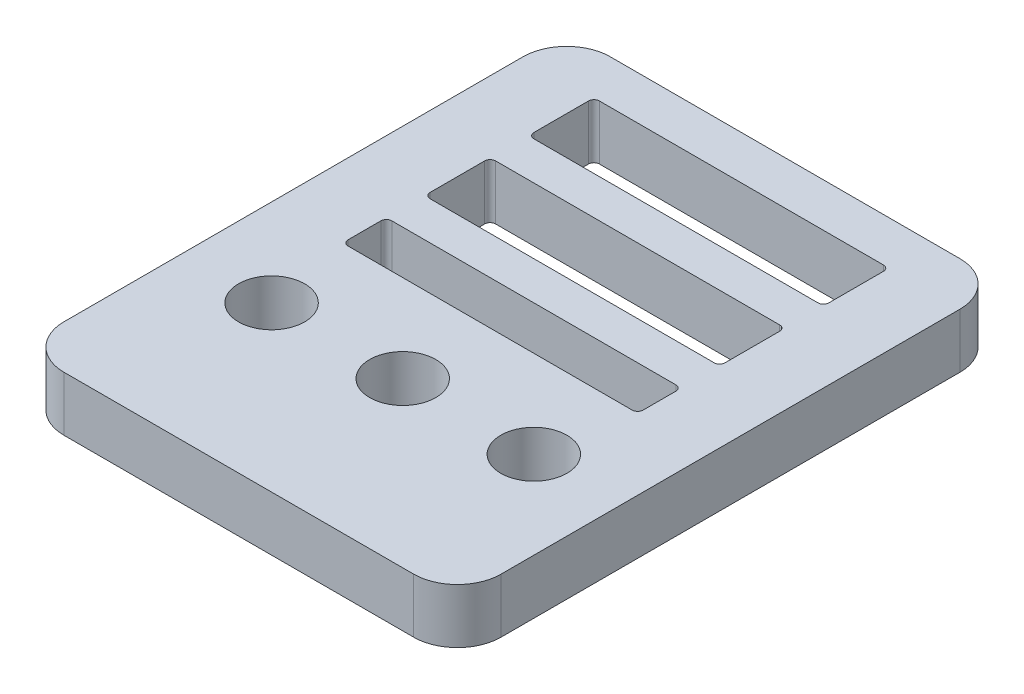
from build123d import *

# Parameters (mm, degrees)
SKETCH1_W           = 40
SKETCH1_H           = 50
BOSS_EXTRUDE1_DEPTH = 5
SKETCH2_W           = 27
SKETCH2_H           = 6
SKETCH2_H_2         = 4
CUT_EXTRUDE1_DEPTH  = 6
SKETCH3_R           = 3.025
CUT_EXTRUDE2_DEPTH  = 6
LPATTERN1_COUNT     = 2
LPATTERN1_PITCH     = 12
LPATTERN1_COL_COUNT = 2
LPATTERN1_COL_PITCH = 12
FILLET1_R           = 4
FILLET2_R           = 0.5


with BuildPart() as part:
    # Sketch1 → Boss-Extrude1 (new body)
    with BuildSketch(Plane(origin=(0, 0, 0), x_dir=(1, 0, 0), z_dir=(0, 1, 0))):
        Rectangle(SKETCH1_W, SKETCH1_H)
    extrude(amount=BOSS_EXTRUDE1_DEPTH)

    # Sketch2 → Cut-Extrude1 (cut, through all)
    with BuildSketch(Plane(origin=(0, 5, 0), x_dir=(1, 0, 0), z_dir=(0, 1, 0))):
        with Locations((0, 18)):
            Rectangle(SKETCH2_W, SKETCH2_H)
        with Locations((0, 8.5)):
            Rectangle(SKETCH2_W, SKETCH2_H)
        Rectangle(SKETCH2_W, SKETCH2_H_2)
    extrude(amount=-CUT_EXTRUDE1_DEPTH, mode=Mode.SUBTRACT)

    # Sketch3 → Cut-Extrude2 (cut, through all)
    with BuildSketch(Plane(origin=(0, 5, 0), x_dir=(1, 0, 0), z_dir=(0, 1, 0))):
        with Locations((0, -10)):
            Circle(SKETCH3_R)
    cut_extrude2 = extrude(amount=-CUT_EXTRUDE2_DEPTH, mode=Mode.SUBTRACT)

    # LPattern1: Cut-Extrude2 ×2
    with Locations(*[(i * LPATTERN1_PITCH, 0, 0) for i in range(1, LPATTERN1_COUNT)]):
        add(cut_extrude2, mode=Mode.SUBTRACT)

    # LPattern1 col: Cut-Extrude2 ×2
    with Locations(*[(-i * LPATTERN1_COL_PITCH, 0, 0) for i in range(1, LPATTERN1_COL_COUNT)]):
        add(cut_extrude2, mode=Mode.SUBTRACT)

    # Fillet1
    fillet1_edges = [part.edges().sort_by_distance(p)[0] for p in [
        (20, 2.5, 25),
        (-20, 2.5, 25),
        (-20, 2.5, -25),
        (20, 2.5, -25),
    ]]
    fillet(fillet1_edges, radius=FILLET1_R)

    # Fillet2
    fillet2_edges = [part.edges().sort_by_distance(p)[0] for p in [
        (13.5, 2.5, -21),
        (13.5, 2.5, -15),
        (-13.5, 2.5, -15),
        (-13.5, 2.5, -21),
        (13.5, 2.5, -11.5),
        (13.5, 2.5, -5.5),
        (-13.5, 2.5, -5.5),
        (-13.5, 2.5, -11.5),
        (13.5, 2.5, -2),
        (13.5, 2.5, 2),
        (-13.5, 2.5, 2),
        (-13.5, 2.5, -2),
    ]]
    fillet(fillet2_edges, radius=FILLET2_R)


solid = part.part
